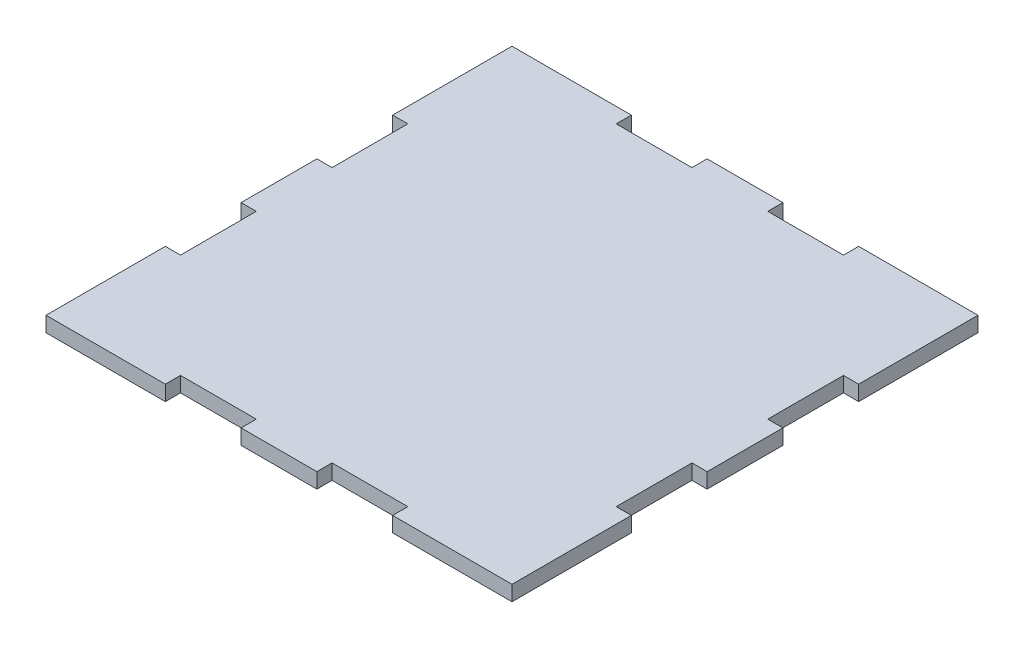
from build123d import *

# Parameters (mm, degrees)
EXTRUDE_1_DEPTH = 4


with BuildPart() as part:
    # Эскиз1 → Бобышка-Вытянуть1 (new body)
    with BuildSketch(Plane(origin=(0, 0, 0), x_dir=(1, 0, 0), z_dir=(0, 1, 0))):
        Polygon((31.5, 0), (31.5, 4), (51.5, 4), (51.5, 0), (71.5, 0), (71.5, 4), (91.5, 4), (91.5, 0), (123, 0), (123, 31.5), (119, 31.5), (119, 51.5), (123, 51.5), (123, 71.5), (119, 71.5), (119, 91.5), (123, 91.5), (123, 123), (91.5, 123), (91.5, 119), (71.5, 119), (71.5, 123), (51.5, 123), (51.5, 119), (31.5, 119), (31.5, 123), (0, 123), (0, 91.5), (4, 91.5), (4, 71.5), (0, 71.5), (0, 51.5), (4, 51.5), (4, 31.5), (0, 31.5), (0, 0), align=None)
    extrude(amount=EXTRUDE_1_DEPTH)


solid = part.part
